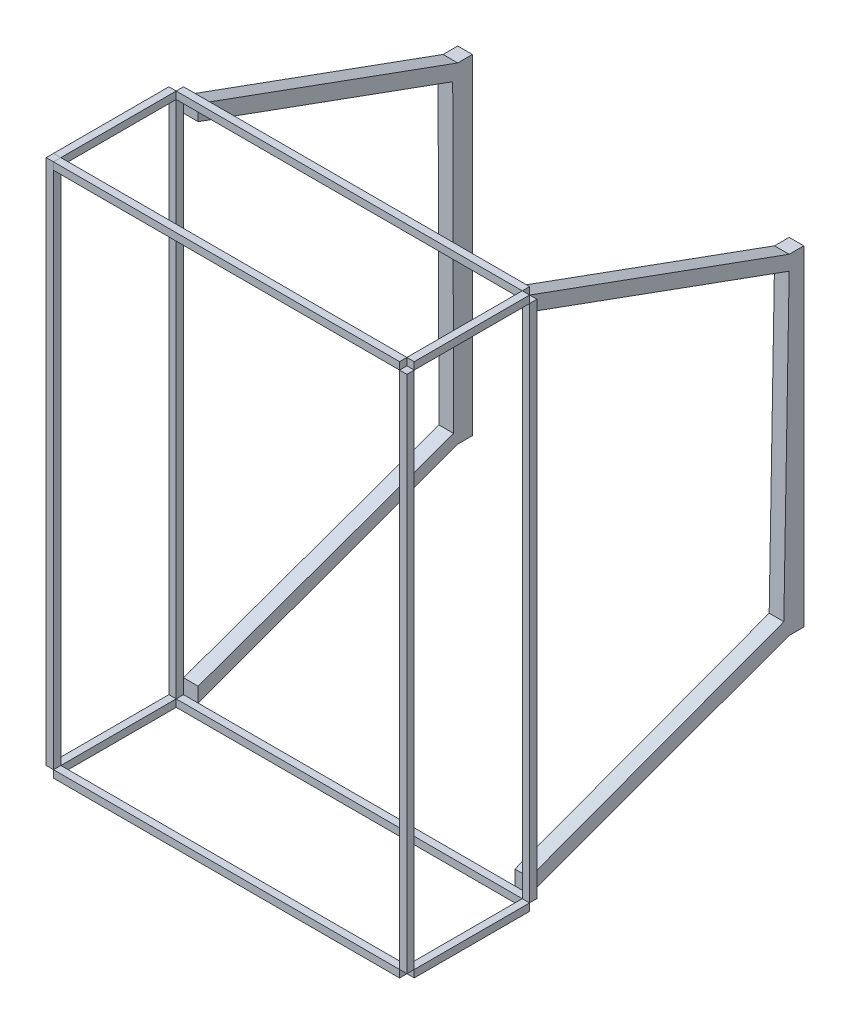
from build123d import *

# Parameters (mm, degrees)
SKETCH1_W                = 6.35
SKETCH1_H                = 6.35
BOSS_EXTRUDE1_DEPTH      = 100
SKETCH4_W                = 6.35
SKETCH4_H                = 6.35
BOSS_EXTRUDE3_DEPTH      = 450
BOSS_EXTRUDE3_DEPTH_BACK = 6.35
SKETCH6_W                = 6.35
SKETCH6_H                = 6.378778746
BOSS_EXTRUDE4_DEPTH      = 100
SKETCH7_W                = 6.35
SKETCH7_H                = 6.35
BOSS_EXTRUDE5_DEPTH      = 300
SKETCH8_W                = 6.35
SKETCH8_H                = 6.378778746
BOSS_EXTRUDE6_DEPTH      = 300
SKETCH10_W               = 6.35
SKETCH10_H               = 6.35
BOSS_EXTRUDE7_DEPTH      = 450
SKETCH12_W               = 6.35
SKETCH12_H               = 6.35
BOSS_EXTRUDE8_DEPTH      = 450
SKETCH16_W               = 6.35
SKETCH16_H               = 6.35
BOSS_EXTRUDE9_DEPTH      = 100
SKETCH20_W               = 6.35
SKETCH20_H               = 6.35
BOSS_EXTRUDE10_DEPTH     = 100
SKETCH21_W               = 6.35
SKETCH21_H               = 6.378778746
BOSS_EXTRUDE11_DEPTH     = 300
SKETCH22_W               = 6.35
SKETCH22_H               = 6.35
BOSS_EXTRUDE12_DEPTH     = 450
SKETCH23_W               = 6.35
SKETCH23_H               = 6.35
BOSS_EXTRUDE13_DEPTH     = 300
BOSS_EXTRUDE20_DEPTH     = 12.7
BOSS_EXTRUDE21_DEPTH     = 12.7
BOSS_EXTRUDE22_DEPTH     = 12.7
BOSS_EXTRUDE23_DEPTH     = 12.7
BOSS_EXTRUDE24_DEPTH     = 12.7
BOSS_EXTRUDE25_DEPTH     = 12.7


with BuildPart() as part:
    # Sketch1 → Boss-Extrude1 (new body)
    with BuildSketch(Plane.XY):
        with Locations((3.175, 3.175)):
            Rectangle(SKETCH1_W, SKETCH1_H)
    extrude(amount=BOSS_EXTRUDE1_DEPTH)


with BuildPart() as body_2:
    # Sketch4 → Boss-Extrude3 (new body, two sides)
    with BuildSketch(Plane(origin=(0, 0, 0), x_dir=(-1, 0, 0), z_dir=(0, -1, 0))) as boss_extrude3_sk:
        with Locations((-3.175, -103.175)):
            Rectangle(SKETCH4_W, SKETCH4_H)
    extrude(amount=BOSS_EXTRUDE3_DEPTH)
    extrude(boss_extrude3_sk.sketch, amount=-BOSS_EXTRUDE3_DEPTH_BACK)


with BuildPart() as body_3:
    # Sketch6 → Boss-Extrude4 (new body)
    with BuildSketch(Plane(origin=(0, 0, 100), x_dir=(-1, 0, 0), z_dir=(0, 0, -1))):
        with Locations((-3.175, -453.189389373)):
            Rectangle(SKETCH6_W, SKETCH6_H)
    extrude(amount=BOSS_EXTRUDE4_DEPTH)


with BuildPart() as body_4:
    # Sketch7 → Boss-Extrude5 (new body)
    with BuildSketch(Plane(origin=(6.35, 0, 0), x_dir=(0, 0, -1), z_dir=(1, 0, 0))):
        with Locations((-103.175, 3.175)):
            Rectangle(SKETCH7_W, SKETCH7_H)
    extrude(amount=BOSS_EXTRUDE5_DEPTH)


with BuildPart() as body_5:
    # Sketch8 → Boss-Extrude6 (new body)
    with BuildSketch(Plane(origin=(6.35, 0, 0), x_dir=(0, 0, -1), z_dir=(1, 0, 0))):
        with Locations((-103.175, -453.189389373)):
            Rectangle(SKETCH8_W, SKETCH8_H)
    extrude(amount=BOSS_EXTRUDE6_DEPTH)


with BuildPart() as body_6:
    # Sketch10 → Boss-Extrude7 (new body)
    with BuildSketch(Plane(origin=(0, -450, 0), x_dir=(1, 0, 0), z_dir=(0, 1, 0))):
        with Locations((309.525, -103.175)):
            Rectangle(SKETCH10_W, SKETCH10_H)
    extrude(amount=BOSS_EXTRUDE7_DEPTH)


with BuildPart() as body_7:
    # Sketch12 → Boss-Extrude8 (new body)
    with BuildSketch(Plane(origin=(0, 0, 0), x_dir=(-1, 0, 0), z_dir=(0, -1, 0))):
        with Locations((-3.175, 3.175)):
            Rectangle(SKETCH12_W, SKETCH12_H)
    extrude(amount=BOSS_EXTRUDE8_DEPTH)


with BuildPart() as body_8:
    # Sketch16 → Boss-Extrude9 (new body)
    with BuildSketch(Plane(origin=(0, 0, 100), x_dir=(-1, 0, 0), z_dir=(0, 0, -1))):
        with Locations((-309.525, -453.175)):
            Rectangle(SKETCH16_W, SKETCH16_H)
    extrude(amount=BOSS_EXTRUDE9_DEPTH)


with BuildPart() as body_9:
    # Sketch20 → Boss-Extrude10 (new body)
    with BuildSketch(Plane(origin=(0, 0, 100), x_dir=(-1, 0, 0), z_dir=(0, 0, -1))):
        with Locations((-309.525, 3.175)):
            Rectangle(SKETCH20_W, SKETCH20_H)
    extrude(amount=BOSS_EXTRUDE10_DEPTH)


with BuildPart() as body_10:
    # Sketch21 → Boss-Extrude11 (new body)
    with BuildSketch(Plane(origin=(6.35, 0, 0), x_dir=(0, 0, -1), z_dir=(1, 0, 0))):
        with Locations((3.175, -453.189389373)):
            Rectangle(SKETCH21_W, SKETCH21_H)
    extrude(amount=BOSS_EXTRUDE11_DEPTH)


with BuildPart() as body_11:
    # Sketch22 → Boss-Extrude12 (new body)
    with BuildSketch(Plane(origin=(0, -450, 0), x_dir=(1, 0, 0), z_dir=(0, 1, 0))):
        with Locations((309.525, 3.175)):
            Rectangle(SKETCH22_W, SKETCH22_H)
    extrude(amount=BOSS_EXTRUDE12_DEPTH)


with BuildPart() as body_12:
    # Sketch23 → Boss-Extrude13 (new body)
    with BuildSketch(Plane.ZY.offset(-306.35)):
        with Locations((-3.175, 3.175)):
            Rectangle(SKETCH23_W, SKETCH23_H)
    extrude(amount=BOSS_EXTRUDE13_DEPTH)


with BuildPart() as body_13:
    # Sketch25 → Boss-Extrude20 (new body)
    with BuildSketch(Plane(origin=(6.35, 0, 0), x_dir=(0, 0, -1), z_dir=(1, 0, 0))):
        Polygon((6.35, 0), (231.35, -81.89330271), (227.00634418, -93.827398994), (6.35, -13.51505771), align=None)
    extrude(amount=BOSS_EXTRUDE20_DEPTH)



with BuildPart() as body_14:
    # Sketch26 → Boss-Extrude21 (new body)
    with BuildSketch(Plane.ZY.offset(-306.35)):
        Polygon((-6.35, 0), (-231.35, -81.89330271), (-231.35, -94.59330271), (-6.35, -12.7), align=None)
    extrude(amount=BOSS_EXTRUDE21_DEPTH)



with BuildPart() as body_15:
    # Sketch27 → Boss-Extrude22 (new body)
    with BuildSketch(Plane.ZY.offset(-306.35)):
        Polygon((-6.35, -450), (-231.35, -368.10669729), (-226.727578025, -355.40669729), (-6.35, -437.3), align=None)
    extrude(amount=BOSS_EXTRUDE22_DEPTH)


with BuildPart() as body_16:
    # Sketch28 → Boss-Extrude23 (new body)
    with BuildSketch(Plane(origin=(6.35, 0, 0), x_dir=(0, 0, -1), z_dir=(1, 0, 0))):
        Polygon((6.35, -450), (231.35, -368.10669729), (227.760753861, -358.24532457), (6.35, -437.3), align=None)
    extrude(amount=BOSS_EXTRUDE23_DEPTH)


with BuildPart() as body_14_1:
    add(body_14.part)

    add(body_15.part)  # Boss-Extrude24 merges body 15
    # Sketch29 → Boss-Extrude24 (add)
    with BuildSketch(Plane(origin=(306.35, 0, 0), x_dir=(0, 0, -1), z_dir=(1, 0, 0))):
        Polygon((231.35, -81.89330271), (231.35, -94.59330271), (226.727578025, -355.40669729), (231.35, -368.10669729), (244.05, -368.10669729), (244.05, -81.89330271), align=None)
    extrude(amount=-BOSS_EXTRUDE24_DEPTH)


with BuildPart() as body_13_1:
    add(body_13.part)

    add(body_16.part)  # Boss-Extrude25 merges body 16
    # Sketch31 → Boss-Extrude25 (add)
    with BuildSketch(Plane.ZY.offset(-6.35)):
        Polygon((-231.35, -81.89330271), (-227.00634418, -93.827398994), (-227.760753861, -358.24532457), (-231.35, -368.10669729), (-244.05, -368.10669729), (-244.05, -81.89330271), align=None)
    extrude(amount=-BOSS_EXTRUDE25_DEPTH)


solid = Compound([part.part, body_2.part, body_3.part, body_4.part, body_5.part, body_6.part, body_7.part, body_8.part, body_9.part, body_10.part, body_11.part, body_12.part, body_14_1.part, body_13_1.part])
